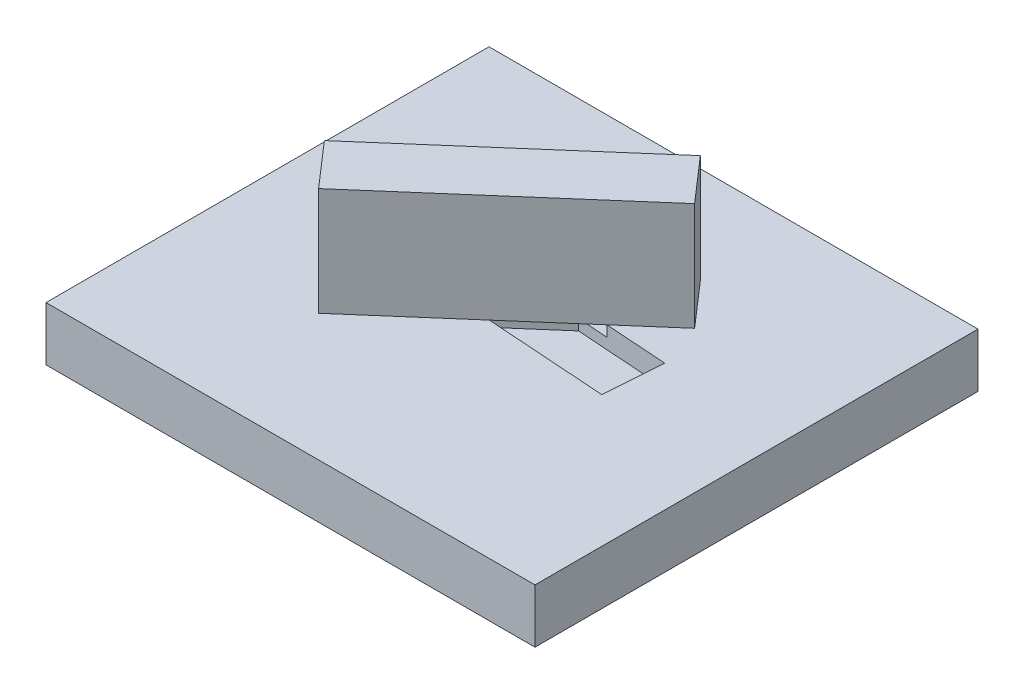
from build123d import *

# Parameters (mm, degrees)
SKIZZE1_W                          = 45.286676114
SKIZZE1_H                          = 41.027038262
AUFSATZ_LINEAR_AUSTRAGEN1_DEPTH    = 5
AUFSATZ_LINEAR_AUSTRAGEN2_DEPTH    = 10
SCHNITT_LINEAR_AUSTRAGEN1_DEPTH    = 1
K_RPER_VERSCHIEBEN_KOPIEREN1_ANGLE = 45
SCHNITT_LINEAR_AUSTRAGEN2_DEPTH    = 2
K_RPER_VERSCHIEBEN_KOPIEREN2_ANGLE = 45
SCHNITT_LINEAR_AUSTRAGEN3_DEPTH    = 7


with BuildPart() as part:
    # Skizze1 → Aufsatz-Linear austragen1 (new body)
    with BuildSketch(Plane(origin=(0, 0, 0), x_dir=(1, 0, 0), z_dir=(0, 1, 0))):
        with Locations((-22.643338057, 20.513519131)):
            Rectangle(SKIZZE1_W, SKIZZE1_H)
    extrude(amount=AUFSATZ_LINEAR_AUSTRAGEN1_DEPTH)

    # Skizze3 → Schnitt-Linear austragen1 (cut)
    with BuildSketch(Plane(origin=(0, 5, 0), x_dir=(1, 0, 0), z_dir=(0, 1, 0))):
        Polygon((-35.388215561, 15.87901822), (-31.805473355, 11.762755891), (-13.187281399, 27.967792593), (-16.770023605, 32.084054922), align=None)
    extrude(amount=-SCHNITT_LINEAR_AUSTRAGEN1_DEPTH, mode=Mode.SUBTRACT)

    # Skizze4 → Schnitt-Linear austragen2 (cut)
    with BuildSketch(Plane(origin=(0, 5, 0), x_dir=(1, 0, 0), z_dir=(0, 1, 0))):
        Polygon((-36.410991195, 25.498593786), (-36.788246892, 20.054575471), (-12.164505765, 18.348217027), (-11.787250068, 23.792235342), align=None)
    extrude(amount=-SCHNITT_LINEAR_AUSTRAGEN2_DEPTH, mode=Mode.SUBTRACT)

    # Skizze5 → Schnitt-Linear austragen3 (cut)
    with BuildSketch(Plane(origin=(0, 5, 0), x_dir=(1, 0, 0), z_dir=(0, 1, 0))):
        Polygon((-32.566555289, 15.68348482), (-31.609939954, 14.584416163), (-16.008941671, 28.163325994), (-16.965557005, 29.262394651), align=None)
    extrude(amount=-SCHNITT_LINEAR_AUSTRAGEN3_DEPTH, mode=Mode.SUBTRACT)


with BuildPart() as body_2:
    # Skizze2 → Aufsatz-Linear austragen2 (new body)
    with BuildSketch(Plane(origin=(0, 5, 0), x_dir=(1, 0, 0), z_dir=(0, 1, 0))):
        Polygon((-35.388215561, 15.87901822), (-16.770023605, 32.084054922), (-13.187281399, 27.967792593), (-31.805473355, 11.762755891), align=None)
    extrude(amount=AUFSATZ_LINEAR_AUSTRAGEN2_DEPTH)


with BuildPart() as body_2_1:
    # K_rper-Verschieben_Kopieren1: moved
    add(body_2.part.rotate(Axis((-24.28774848, 0, -21.923405407), (0, -1, 0)), K_RPER_VERSCHIEBEN_KOPIEREN1_ANGLE))


with BuildPart() as body_2_2:
    # K_rper-Verschieben_Kopieren2: moved
    add(body_2_1.part.rotate(Axis((-24.28774848, 0, -21.923405407), (0, 1, 0)), K_RPER_VERSCHIEBEN_KOPIEREN2_ANGLE))


solid = Compound([part.part, body_2_2.part])
